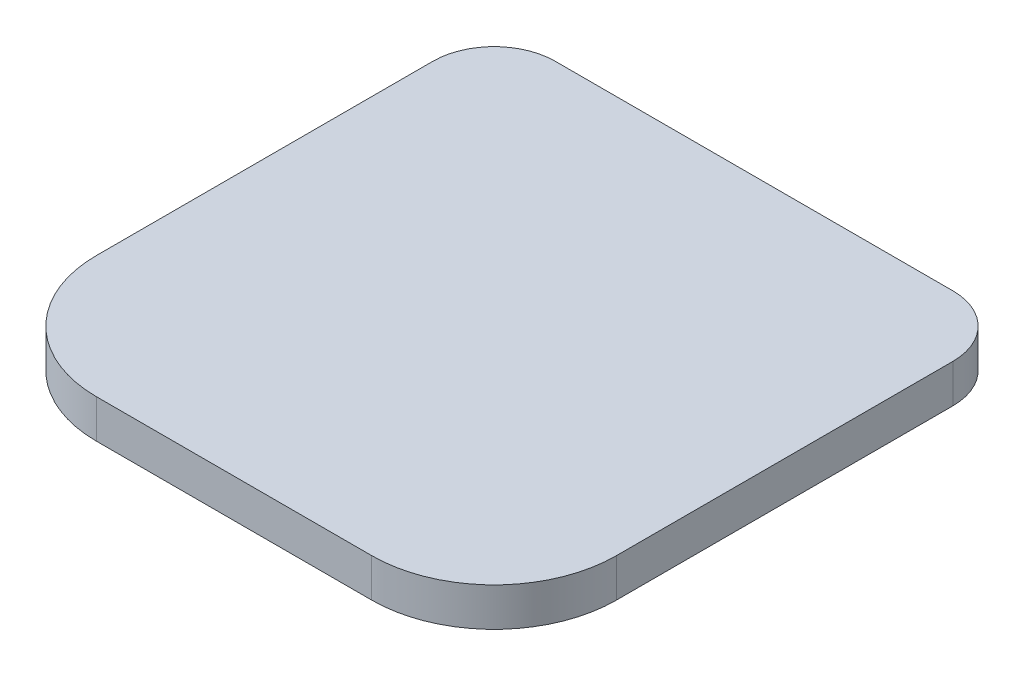
from build123d import *

# Parameters (mm, degrees)
SKETCH1_W           = 85
SKETCH1_H           = 85
BOSS_EXTRUDE1_DEPTH = 6.3
FILLET1_R           = 10
FILLET2_R           = 20


with BuildPart() as part:
    # Sketch1 → Boss-Extrude1 (new body)
    with BuildSketch(Plane(origin=(0, 0, 0), x_dir=(1, 0, 0), z_dir=(0, 1, 0))):
        with Locations((42.5, 42.5)):
            Rectangle(SKETCH1_W, SKETCH1_H)
    extrude(amount=BOSS_EXTRUDE1_DEPTH)

    # Fillet1
    fillet1_edges = [part.edges().sort_by_distance(p)[0] for p in [
        (0, 3.15, -85),
        (85, 3.15, -85),
    ]]
    fillet(fillet1_edges, radius=FILLET1_R)

    # Fillet2
    fillet2_edges = [part.edges().sort_by_distance(p)[0] for p in [
        (85, 3.15, 0),
        (0, 3.15, 0),
    ]]
    fillet(fillet2_edges, radius=FILLET2_R)


solid = part.part
